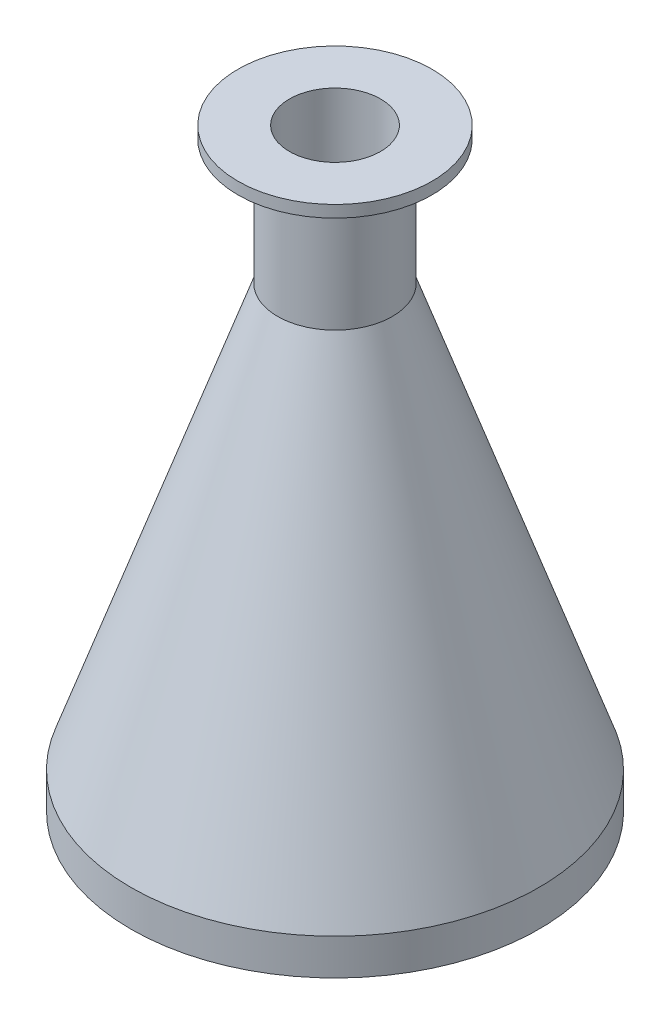
from build123d import *


with BuildPart() as part:
    # Sketch1 → Revolve1 (revolve)
    with BuildSketch(Plane.XY, mode=Mode.PRIVATE) as revolve1_sk:
        Polygon((11.5, 150), (11.5, 114.942528736), (51.5, 0), (51.5, 9.127775749), (14.5, 115.44961483), (14.5, 147), (24.5, 147), (24.5, 150), (14.5, 150), align=None)
    revolve(revolve1_sk.sketch.rotate(Axis((0, 0, 0), (0, 1, 0)), 90), axis=Axis((0, 0, 0), (0, 1, 0)))  # turned: the seam where the file's is


solid = part.part
